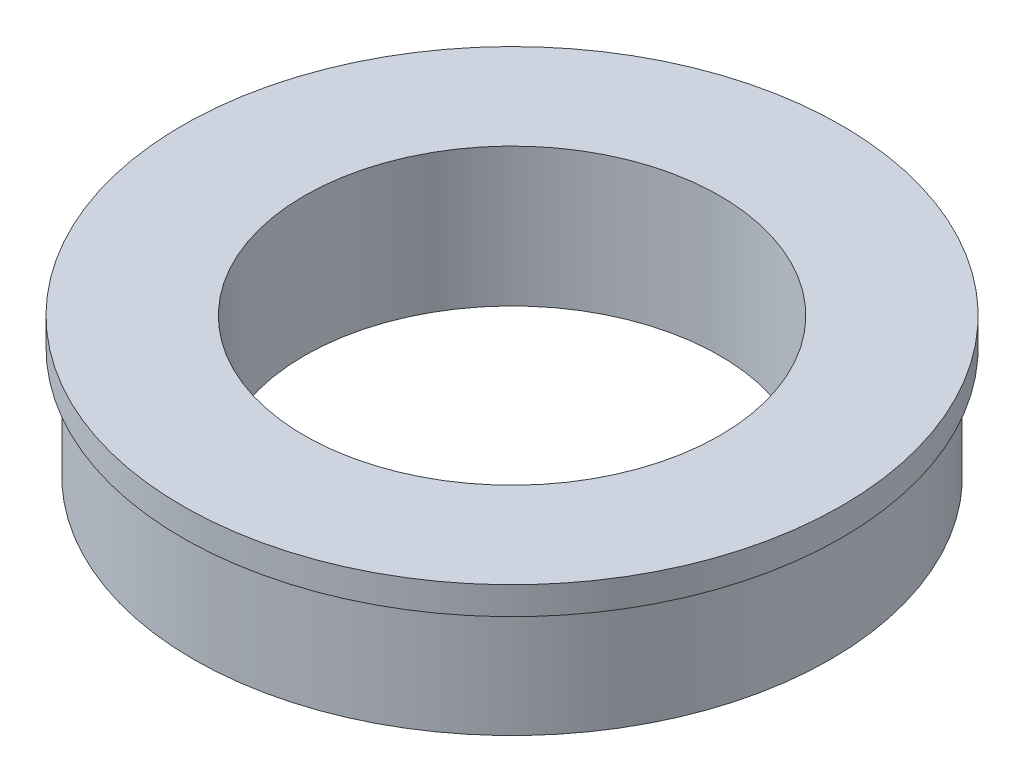
from build123d import *


with BuildPart() as part:
    # Sketch2 → Revolve1 (revolve)
    with BuildSketch(Plane.XY):
        Polygon((4.7625, 9.955346386), (4.7625, 6.780346386), (7.3025, 6.780346386), (7.3025, 9.320346386), (7.5565, 9.320346386), (7.5565, 9.955346386), align=None)
    revolve(axis=Axis((0, -19.422966867, 0), (0, 1, 0)))


solid = part.part
